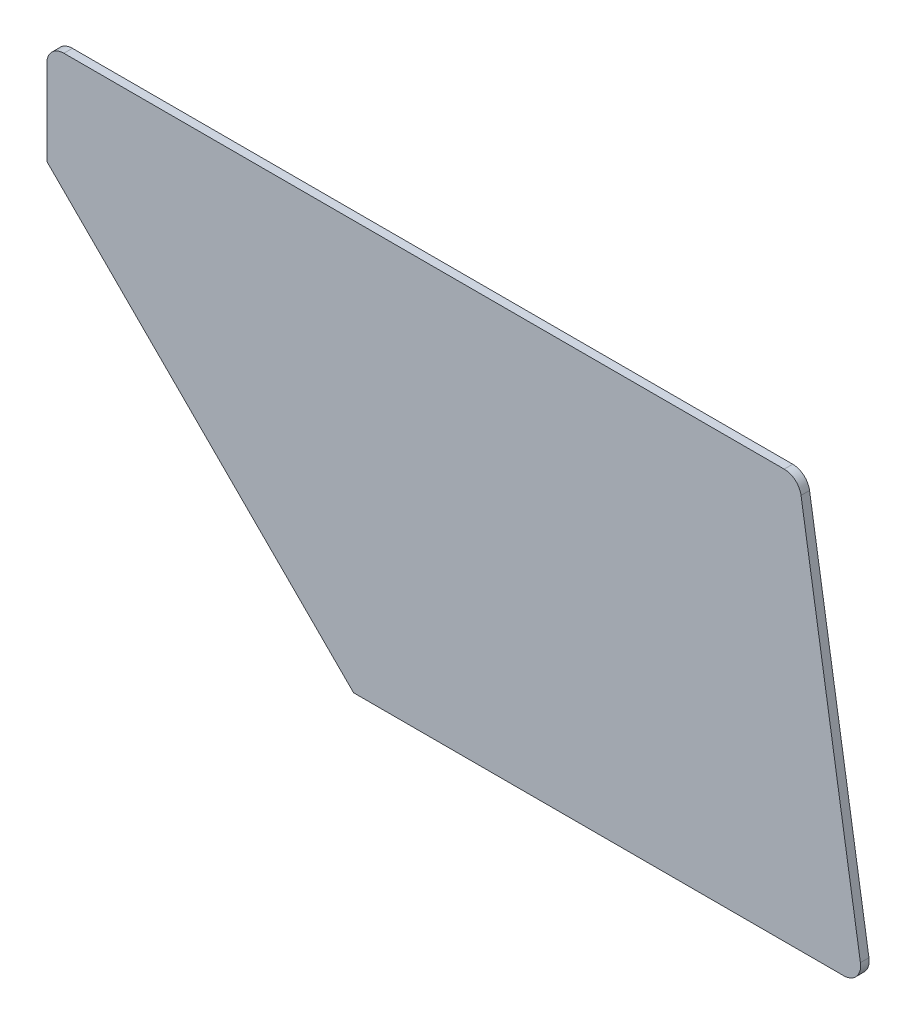
from build123d import *

# Parameters (mm, degrees)
BOSS_EXTRUDE1_DEPTH = 3.175


with BuildPart() as part:
    # Sketch1 → Boss-Extrude1 (new body)
    with BuildSketch(Plane.XY):
        with BuildLine():
            Line((0, -6.35), (0, -38.1))
            Line((0, -38.1), (114.3, -152.4))
            Line((114.3, -152.4), (296.8625, -152.4))
            ThreePointArc((296.8625, -152.4), (301.691077882, -150.173995107), (303.134320963, -145.056641147))
            Line((303.134320963, -145.056641147), (281.008014649, -5.356641147))
            ThreePointArc((281.008014649, -5.356641147), (278.860188794, -1.521422118), (274.736193687, 0))
            Line((274.736193687, 0), (6.35, 0))
            ThreePointArc((6.35, 0), (1.859871939, -1.859871939), (0, -6.35))
        make_face()
    extrude(amount=BOSS_EXTRUDE1_DEPTH)


solid = part.part
